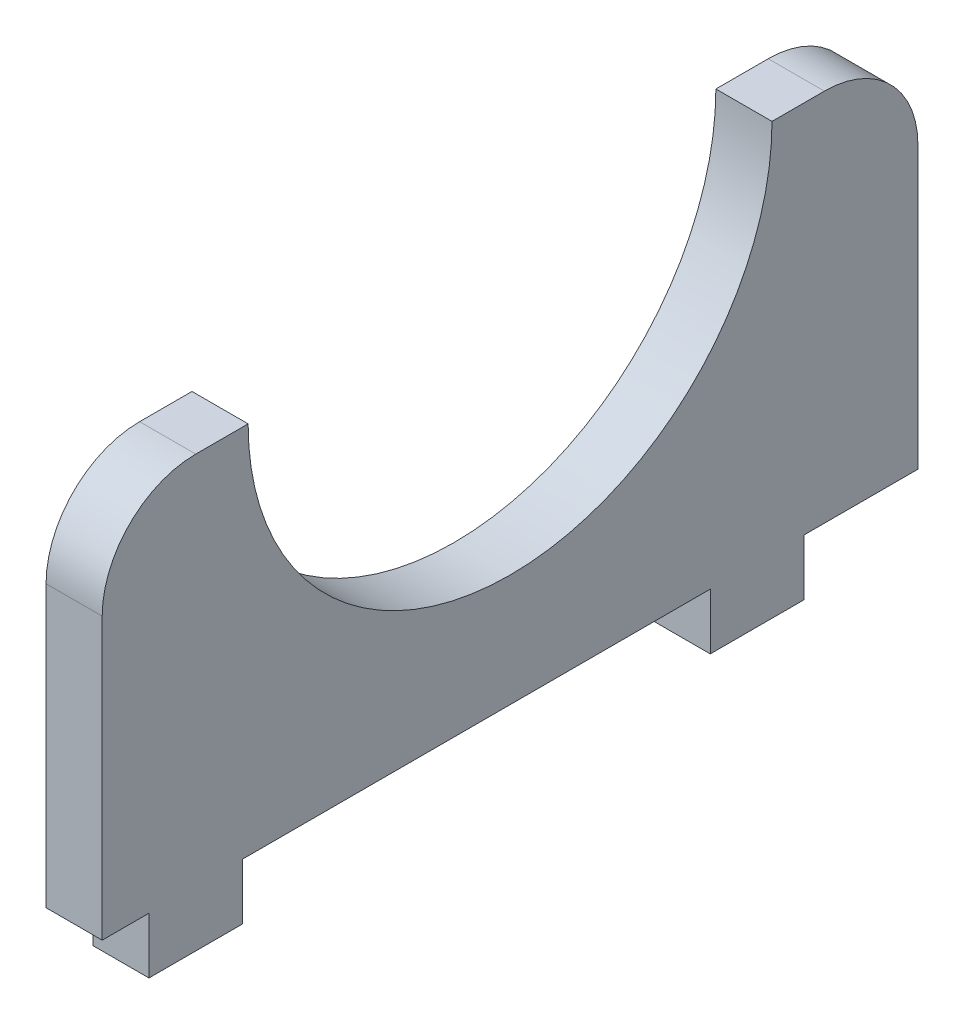
from build123d import *

# Parameters (mm, degrees)
SKETCH1_W           = 43.6
SKETCH1_H           = 20
BOSS_EXTRUDE1_DEPTH = 3
SKETCH4_R           = 14
CUT_EXTRUDE1_DEPTH  = 4
FILLET1_R           = 5
SKETCH3_W           = 3
SKETCH3_H           = 5
BOSS_EXTRUDE2_DEPTH = 3
LPATTERN1_COUNT     = 2
LPATTERN1_PITCH     = 30


with BuildPart() as part:
    # Sketch1 → Boss-Extrude1 (new body)
    with BuildSketch(Plane(origin=(0, 0, 0), x_dir=(0, 0, -1), z_dir=(1, 0, 0))):
        with Locations((-8.2, -1.75)):
            Rectangle(SKETCH1_W, SKETCH1_H)
    extrude(amount=BOSS_EXTRUDE1_DEPTH)

    # Sketch4 → Cut-Extrude1 (cut, through all)
    with BuildSketch(Plane(origin=(3, 0, 0), x_dir=(0, 0, -1), z_dir=(1, 0, 0))):
        with Locations((-8.2, 8.25)):
            Circle(SKETCH4_R)
    extrude(amount=-CUT_EXTRUDE1_DEPTH, mode=Mode.SUBTRACT)

    # Fillet1
    fillet1_edges = [part.edges().sort_by_distance(p)[0] for p in [
        (1.5, 8.25, 30),
        (1.5, 8.25, -13.6),
    ]]
    fillet(fillet1_edges, radius=FILLET1_R)

    # Sketch3 → Boss-Extrude2 (add)
    with BuildSketch(Plane.XZ.offset(11.75)):
        with Locations((1.5, 25)):
            Rectangle(SKETCH3_W, SKETCH3_H)
    boss_extrude2 = extrude(amount=BOSS_EXTRUDE2_DEPTH)

    # LPattern1: Boss-Extrude2 ×2
    with Locations(*[(0, 0, -i * LPATTERN1_PITCH) for i in range(1, LPATTERN1_COUNT)]):
        add(boss_extrude2)


solid = part.part
